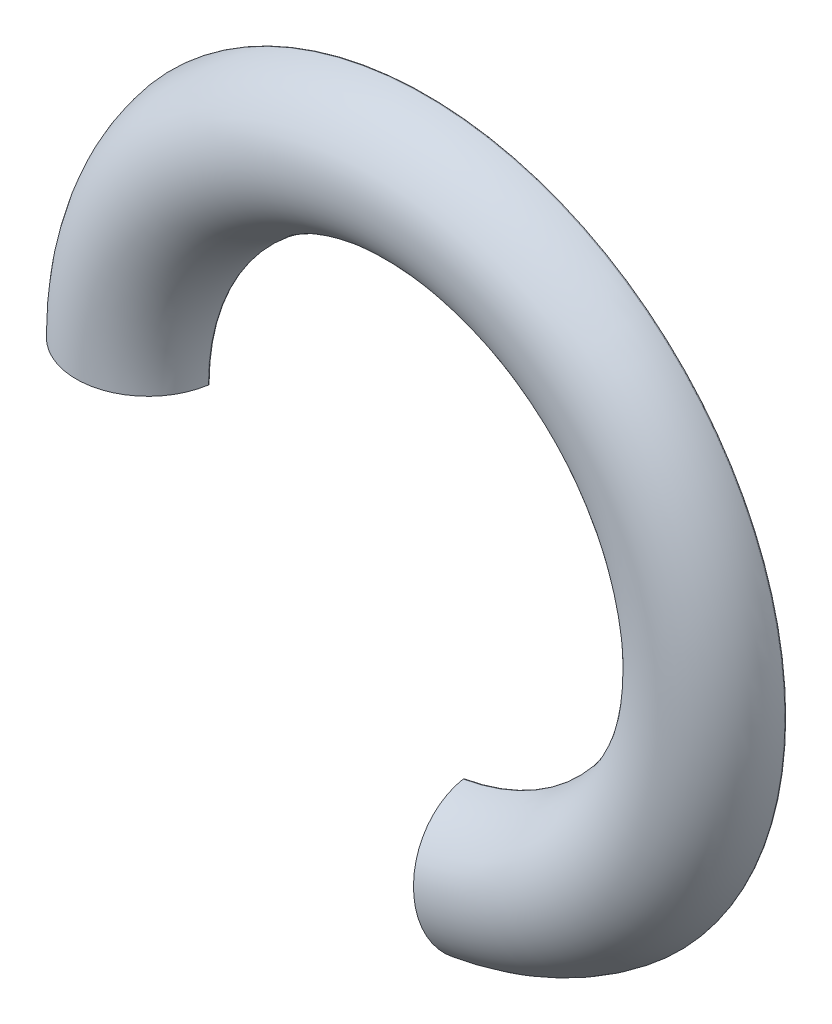
from build123d import *

# Parameters (mm, degrees)
CUTOUT_DEPTH      = 75.809924734
CUTOUT_DEPTH_BACK = 75.809924734


with BuildPart() as part:
    # Main Belt: sweep along a path in Belt Path
    with BuildLine(Plane.XY) as main_belt_path:
        CenterArc((0, 0), 42, 0, 360)
    # Belt Profile → Main Belt (sweep)
    with BuildSketch(Plane(origin=(0, 0, 0), x_dir=(1, 0, 0), z_dir=(0, 1, 0))):
        with BuildLine():
            Line((-32.940198678, -1.4), (-31.825030713, -1.4))
            ThreePointArc((-31.825030713, -1.4), (-31.673021515, -1.470026142), (-31.627458493, -1.631067961))
            ThreePointArc((-31.627458493, -1.631067961), (-42, -10.5), (-52.372541507, -1.631067961))
            ThreePointArc((-52.372541507, -1.631067961), (-52.326978485, -1.470026142), (-52.174969287, -1.4))
            Line((-52.174969287, -1.4), (-51.059801322, -1.4))
            ThreePointArc((-51.059801322, -1.4), (-50.931264405, -1.446773824), (-50.86284912, -1.565217391))
            ThreePointArc((-50.86284912, -1.565217391), (-42, -9), (-33.13715088, -1.565217391))
            ThreePointArc((-33.13715088, -1.565217391), (-33.068735595, -1.446773824), (-32.940198678, -1.4))
        make_face()
    sweep(path=main_belt_path.line)

    # Test Cutout Sketch → Cutout (cut, two sides: drawn at the far end of the back side and taken through both)
    with BuildSketch(Plane.XY.offset(-CUTOUT_DEPTH_BACK)):
        with BuildLine():
            Line((0, 0), (10.41889066, -59.088465181))
            ThreePointArc((10.41889066, -59.088465181), (-38.567256581, -45.962666587), (-60, 0))
            Line((-60, 0), (0, 0))
        make_face()
    extrude(amount=CUTOUT_DEPTH + CUTOUT_DEPTH_BACK, mode=Mode.SUBTRACT)


solid = part.part
